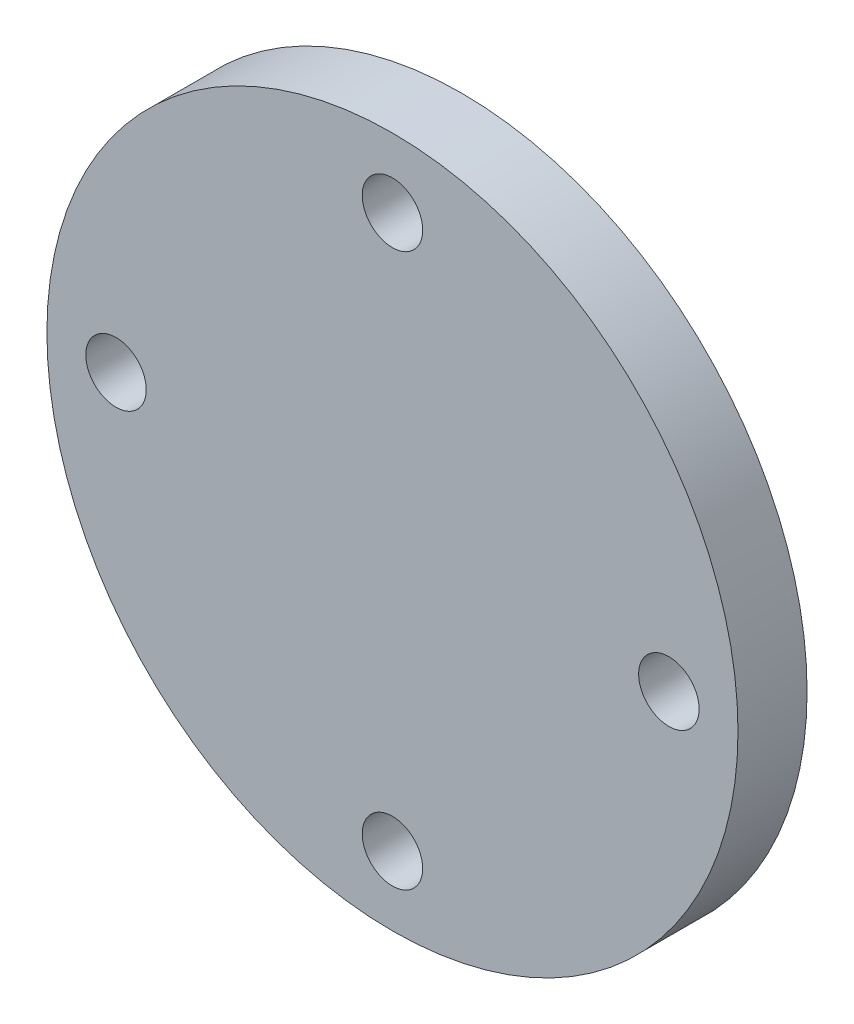
from build123d import *

# Parameters (mm, degrees)
SKETCH1_R           = 63.5
SKETCH1_R_2         = 5.55625
BOSS_EXTRUDE1_DEPTH = 12.7
SKETCH2_R           = 12.7
BOSS_EXTRUDE2_DEPTH = 35.56


with BuildPart() as part:
    # Sketch1 → Boss-Extrude1 (new body)
    with BuildSketch(Plane.XY):
        Circle(SKETCH1_R)
        with Locations((-50.8, 0)):
            Circle(SKETCH1_R_2, mode=Mode.SUBTRACT)
        with Locations((0, 50.8)):
            Circle(SKETCH1_R_2, mode=Mode.SUBTRACT)
        with Locations((50.8, 0)):
            Circle(SKETCH1_R_2, mode=Mode.SUBTRACT)
        with Locations((0, -50.8)):
            Circle(SKETCH1_R_2, mode=Mode.SUBTRACT)
    extrude(amount=BOSS_EXTRUDE1_DEPTH)

    # Sketch2 → Boss-Extrude2 (add)
    with BuildSketch(Plane(origin=(0, 0, 0), x_dir=(-1, 0, 0), z_dir=(0, 0, -1))):
        Circle(SKETCH2_R)
        with BuildLine():
            Line((-2.413, 7.561834252), (-2.413, 3.1115))
            Line((-2.413, 3.1115), (2.413, 3.1115))
            Line((2.413, 3.1115), (2.413, 7.561834252))
            ThreePointArc((2.413, 7.561834252), (0, -7.9375), (-2.413, 7.561834252))
        make_face(mode=Mode.SUBTRACT)
    extrude(amount=BOSS_EXTRUDE2_DEPTH)


solid = part.part
